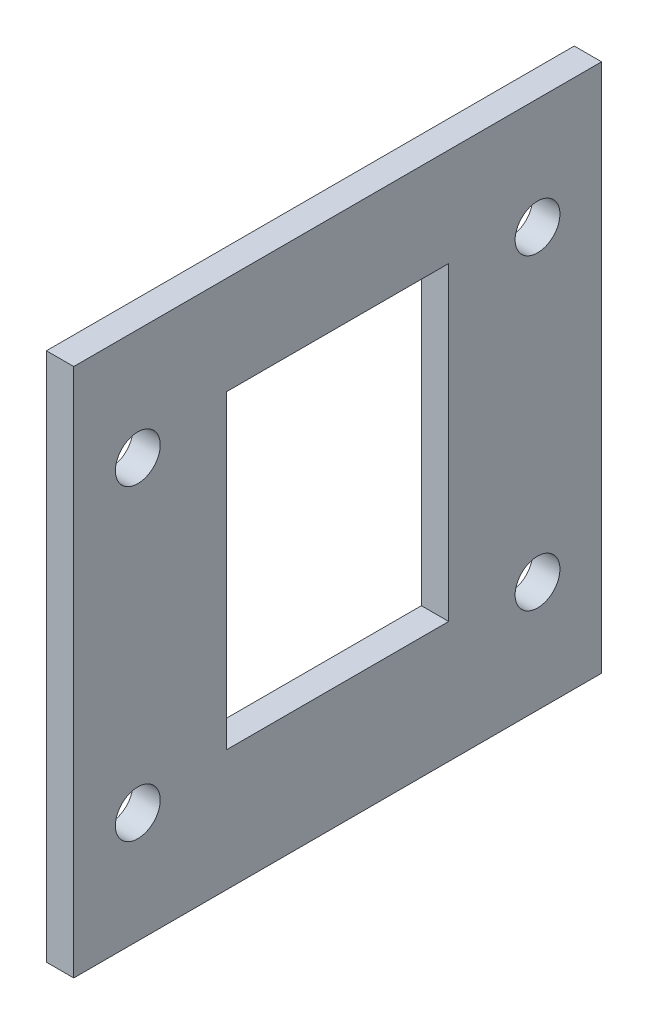
from build123d import *

# Parameters (mm, degrees)
SKETCH1_W           = 61.8
SKETCH1_H           = 62
BOSS_EXTRUDE1_DEPTH = 3.2
CUT_EXTRUDE1_REACH  = 5.2
SKETCH2_W           = 26
SKETCH2_H           = 36.3
CUT_EXTRUDE2_REACH  = 5.2
SKETCH3_R           = 2.625


with BuildPart() as part:
    # Sketch1 → Boss-Extrude1 (new body)
    with BuildSketch(Plane(origin=(0, 0, 0), x_dir=(0, 0, -1), z_dir=(1, 0, 0))):
        with Locations((30.9, 31)):
            Rectangle(SKETCH1_W, SKETCH1_H)
    extrude(amount=BOSS_EXTRUDE1_DEPTH)

    # Sketch2 → Cut-Extrude1 (cut, up to next)
    with BuildSketch(Plane(origin=(3.2, 0, 0), x_dir=(0, 0, -1), z_dir=(1, 0, 0)), mode=Mode.PRIVATE) as cut_extrude1_sk1:
        with Locations((30.9, 32.35)):
            Rectangle(SKETCH2_W, SKETCH2_H)
    cut_extrude1_tool1 = extrude(cut_extrude1_sk1.sketch, amount=-CUT_EXTRUDE1_REACH, mode=Mode.PRIVATE) & part.part
    add(cut_extrude1_tool1.solids().sort_by_distance((3.2, 32.35, -30.9))[0], mode=Mode.SUBTRACT)

    # Sketch3 → Cut-Extrude2 (cut, up to next)
    with BuildSketch(Plane.ZY, mode=Mode.PRIVATE) as cut_extrude2_sk1:
        with Locations((-7.5, 49)):
            Circle(SKETCH3_R)
    cut_extrude2_tool1 = extrude(cut_extrude2_sk1.sketch, amount=-CUT_EXTRUDE2_REACH, mode=Mode.PRIVATE) & part.part
    add(cut_extrude2_tool1.solids().sort_by_distance((0, 49, -7.5))[0], mode=Mode.SUBTRACT)
    # Sketch3 → Cut-Extrude2 (cut, up to next)
    with BuildSketch(Plane.ZY, mode=Mode.PRIVATE) as cut_extrude2_sk2:
        with Locations((-7.5, 13)):
            Circle(SKETCH3_R)
    cut_extrude2_tool2 = extrude(cut_extrude2_sk2.sketch, amount=-CUT_EXTRUDE2_REACH, mode=Mode.PRIVATE) & part.part
    add(cut_extrude2_tool2.solids().sort_by_distance((0, 13, -7.5))[0], mode=Mode.SUBTRACT)
    # Sketch3 → Cut-Extrude2 (cut, up to next)
    with BuildSketch(Plane.ZY, mode=Mode.PRIVATE) as cut_extrude2_sk3:
        with Locations((-54.3, 49)):
            Circle(SKETCH3_R)
    cut_extrude2_tool3 = extrude(cut_extrude2_sk3.sketch, amount=-CUT_EXTRUDE2_REACH, mode=Mode.PRIVATE) & part.part
    add(cut_extrude2_tool3.solids().sort_by_distance((0, 49, -54.3))[0], mode=Mode.SUBTRACT)
    # Sketch3 → Cut-Extrude2 (cut, up to next)
    with BuildSketch(Plane.ZY, mode=Mode.PRIVATE) as cut_extrude2_sk4:
        with Locations((-54.3, 13)):
            Circle(SKETCH3_R)
    cut_extrude2_tool4 = extrude(cut_extrude2_sk4.sketch, amount=-CUT_EXTRUDE2_REACH, mode=Mode.PRIVATE) & part.part
    add(cut_extrude2_tool4.solids().sort_by_distance((0, 13, -54.3))[0], mode=Mode.SUBTRACT)


solid = part.part
